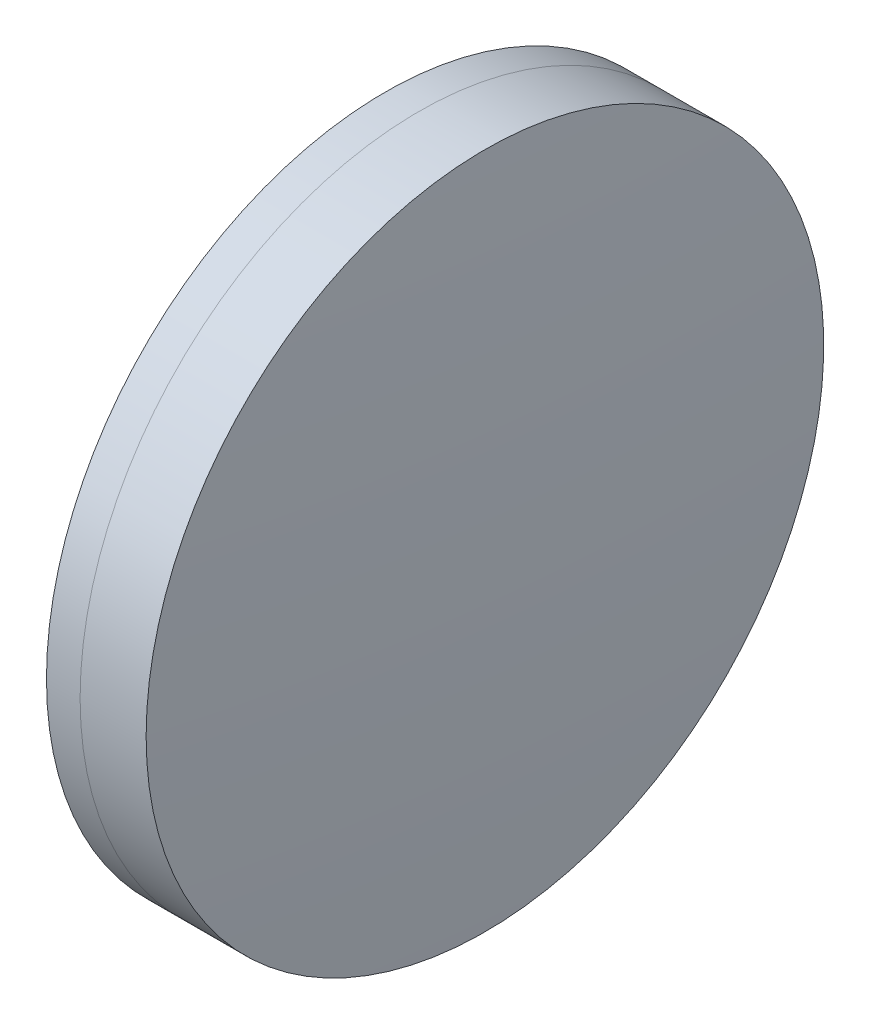
from build123d import *


with BuildPart() as part:
    # 草图1 one side → 旋转1 (revolve)
    with BuildSketch(Plane(origin=(0, 0, 0), x_dir=(1, 0, 0), z_dir=(0, 1, 0)), mode=Mode.PRIVATE) as revolve_1_sk:
        with BuildLine():
            ThreePointArc((259.136093298, 15.75), (258.381201118, 7.891075297), (258.129228187, 0))
            Line((258.129228187, 0), (262.239228187, 0))
            ThreePointArc((262.239228187, 0), (261.853439803, 7.912530273), (260.699734351, 15.75))
            Line((260.699734351, 15.75), (259.136093298, 15.75))
        make_face()
    revolve(revolve_1_sk.sketch.rotate(Axis((124.523309526, 0, 0), (1, 0, 0)), 180), axis=Axis((124.523309526, 0, 0), (1, 0, 0)))  # turned: the seam where the file's is


with BuildPart() as body_2:
    # 草图2 one side → 旋转3 (revolve)
    with BuildSketch(Plane(origin=(0, 0, 0), x_dir=(1, 0, 0), z_dir=(0, 1, 0)), mode=Mode.PRIVATE) as revolve_3_sk:
        with BuildLine():
            Line((263.768972645, 15.75), (260.699734351, 15.75))
            ThreePointArc((260.699734351, 15.75), (261.853439803, 7.912530273), (262.239228187, 0))
            Line((262.239228187, 0), (264.239228187, 0))
            ThreePointArc((264.239228187, 0), (264.121638112, 7.878509381), (263.768972645, 15.75))
        make_face()
    revolve(revolve_3_sk.sketch.rotate(Axis((-0.551919993, 0, 0), (1, 0, 0)), 180), axis=Axis((-0.551919993, 0, 0), (1, 0, 0)))  # turned: the seam where the file's is


solid = Compound([part.part, body_2.part])
